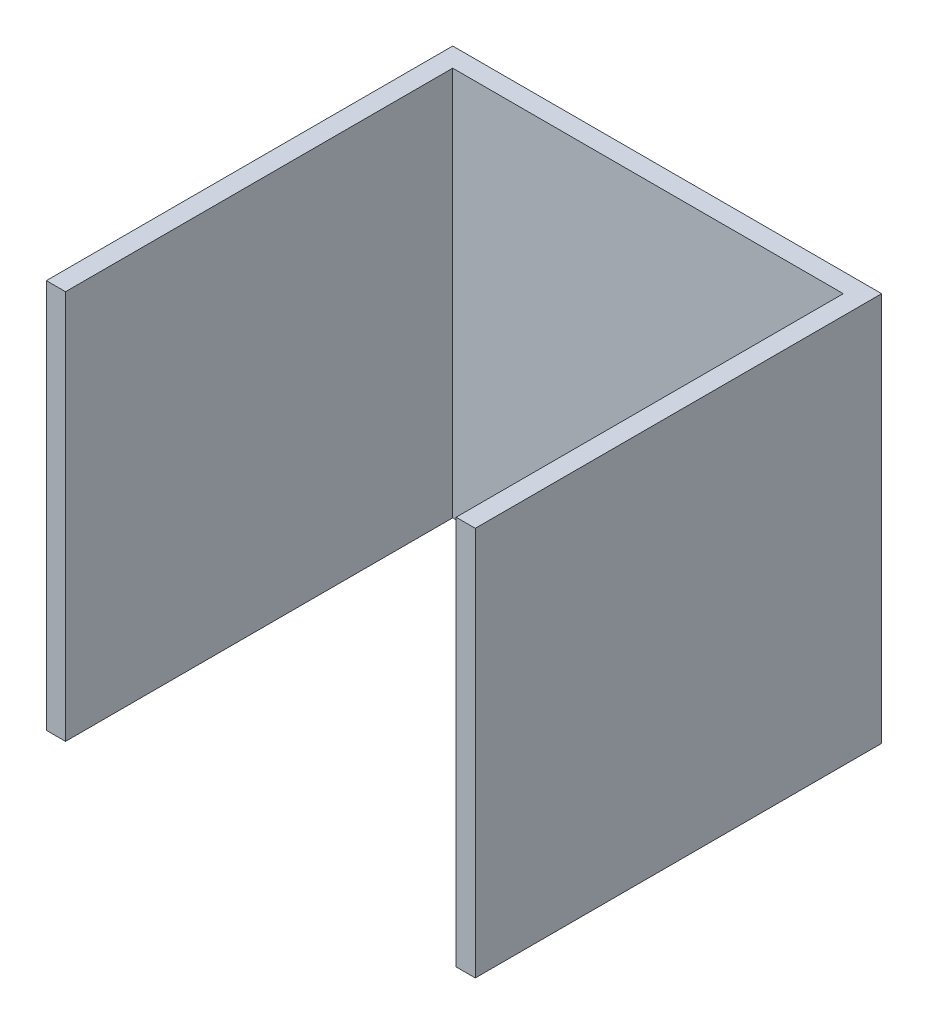
from build123d import *

# Parameters (mm, degrees)
BOSS_EXTRUDE1_DEPTH = 345


with BuildPart() as part:
    # Sketch2 → Boss-Extrude1 (new body)
    with BuildSketch(Plane(origin=(0, 0, 0), x_dir=(1, 0, 0), z_dir=(0, 1, 0))):
        Polygon((17, 0), (17, 343), (363, 343), (363, 0), (380, 0), (380, 360), (0, 360), (0, 0), align=None)
    extrude(amount=BOSS_EXTRUDE1_DEPTH)


solid = part.part
